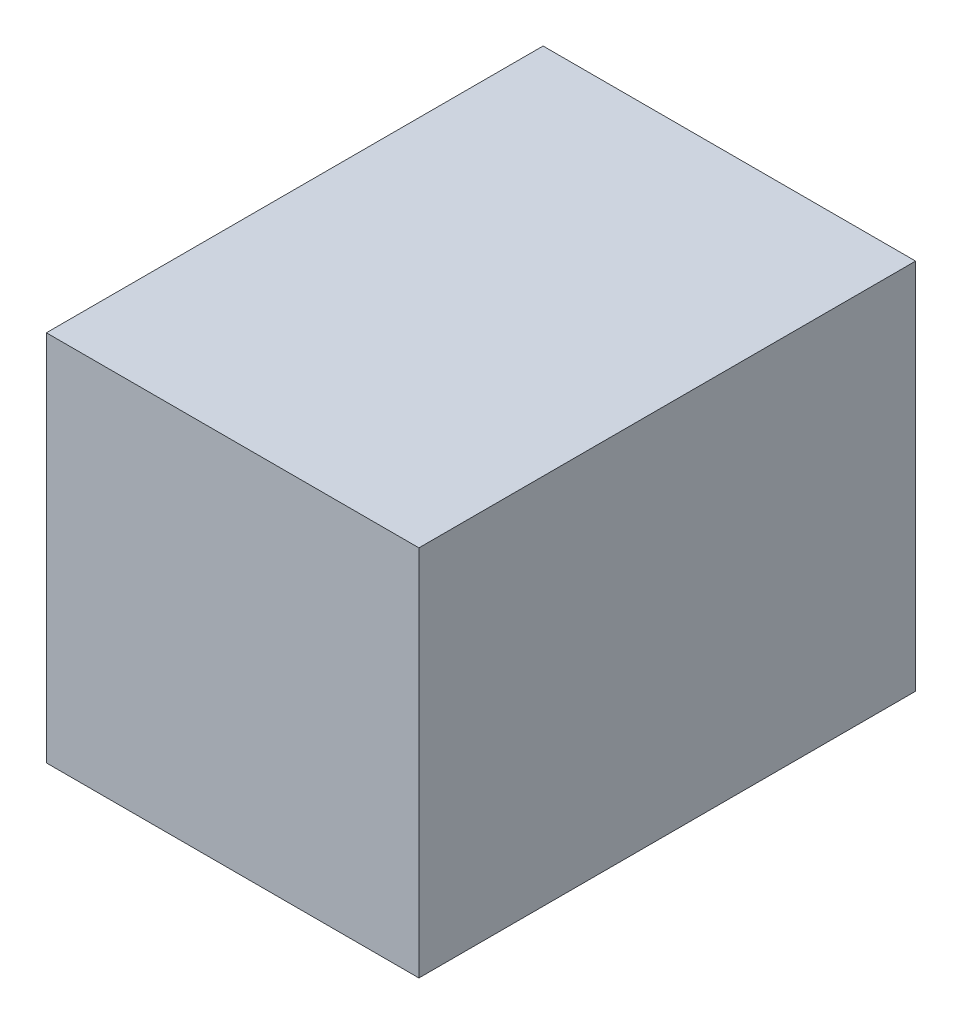
from build123d import *

# Parameters (mm, degrees)
ESQUISSE1_W        = 60
ESQUISSE1_H        = 60
BOSS_EXTRU_1_DEPTH = 80


with BuildPart() as part:
    # Esquisse1 → Boss.-Extru.1 (new body)
    with BuildSketch(Plane.XY):
        with Locations((-71.855476328, -5.483412604)):
            Rectangle(ESQUISSE1_W, ESQUISSE1_H)
    extrude(amount=BOSS_EXTRU_1_DEPTH)


solid = part.part
